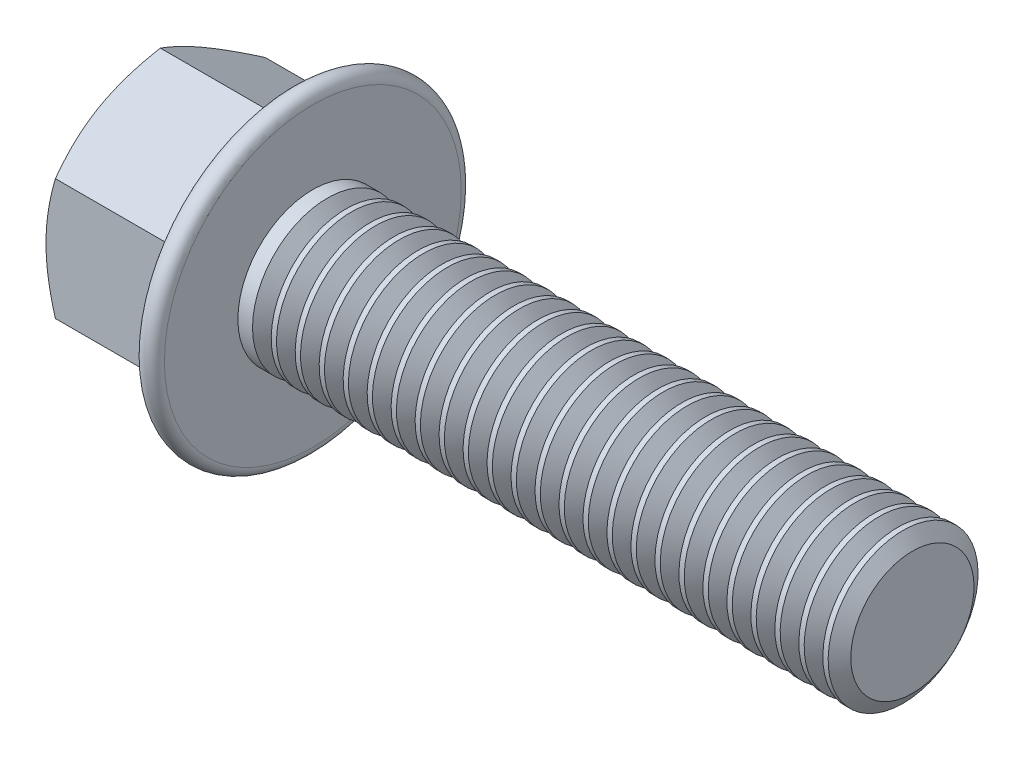
from build123d import *

# Parameters (mm, degrees)
SKETCH2_R         = 4.081986143
HEX_DIE_DEPTH     = 5.4
FLANGEHEXFILLET_R = 0.3
SKETCH4_R         = 3.0625
INDENT_DEPTH      = 0.45
THDSCHPAT_COUNT   = 25
THDSCHPAT_PITCH   = 0.8


with BuildPart() as part:
    # BodySke → Base-Revolve (revolve)
    with BuildSketch(Plane.XY, mode=Mode.PRIVATE) as base_revolve_sk:
        Polygon((5.4, 2.5), (5.4, 4.041570439), (0.312675839, 4.041570439), (0, 3.5), (0, 0), (25.4, 0), (25.4, 2.5), align=None)
    revolve(base_revolve_sk.sketch.rotate(Axis((-25.4, 0, 0), (1, 0, 0)), 90), axis=Axis((-25.4, 0, 0), (1, 0, 0)))

    # Sketch2 → Hex-Die (cut)
    with BuildSketch(Plane(origin=(0, 0, 0), x_dir=(0, 0, -1), z_dir=(1, 0, 0))):
        Circle(SKETCH2_R)
        Polygon((-3.5, 2.020725951), (0, 4.041451902), (3.5, 2.020725951), (3.5, -2.020725951), (0, -4.041451902), (-3.5, -2.020725951), align=None, mode=Mode.SUBTRACT)
    extrude(amount=HEX_DIE_DEPTH, mode=Mode.SUBTRACT)

    # Sketch5 → Flange (revolve)
    with BuildSketch(Plane.XY, mode=Mode.PRIVATE) as flange_sk:
        with BuildLine():
            Line((2.87588512, 0), (4.721107583, 5.06970705))
            ThreePointArc((4.721107583, 5.06970705), (5.110776862, 5.294682714), (5.4, 4.95))
            Line((5.4, 4.95), (5.4, 0))
            Line((5.4, 0), (2.87588512, 0))
        make_face()
    revolve(flange_sk.sketch.rotate(Axis((0, 0, 0), (1, 0, 0)), 90), axis=Axis((0, 0, 0), (1, 0, 0)))

    # FlangeHexFillet
    flangehexfillet_edges = [part.edges().sort_by_distance(p)[0] for p in [
        (4.202243751, 1.014770507, 3.5),
        (4.149780944, 3.031088927, 1.75),
        (4.149780944, 3.031088927, -1.75),
        (4.14978094, 0, -3.5),
        (4.149780944, -3.031088927, -1.75),
        (4.149780944, -3.031088927, 1.75),
        (4.202243751, -1.014770507, 3.5),
    ]]
    fillet(flangehexfillet_edges, radius=FLANGEHEXFILLET_R)

    # Sketch4 → Indent (cut)
    with BuildSketch(Plane(origin=(0, 0, 0), x_dir=(0, 0, -1), z_dir=(1, 0, 0))):
        Circle(SKETCH4_R)
    extrude(amount=INDENT_DEPTH, mode=Mode.SUBTRACT)

    # ThdSchSke → ThreadSchematic (revolve, cut)
    with BuildSketch(Plane.XY):
        Polygon((6.2, -2.055), (5.888407645, -2.5), (5.888407645, -3.125), (6.511592355, -3.125), (6.511592355, -2.5), align=None)
    threadschematic = revolve(axis=Axis((-3.175, 0, 0), (1, 0, 0)), mode=Mode.SUBTRACT)

    # ThdSchPat: ThreadSchematic ×25
    with Locations(*[(i * THDSCHPAT_PITCH, 0, 0) for i in range(1, THDSCHPAT_COUNT)]):
        add(threadschematic, mode=Mode.SUBTRACT)


solid = part.part
